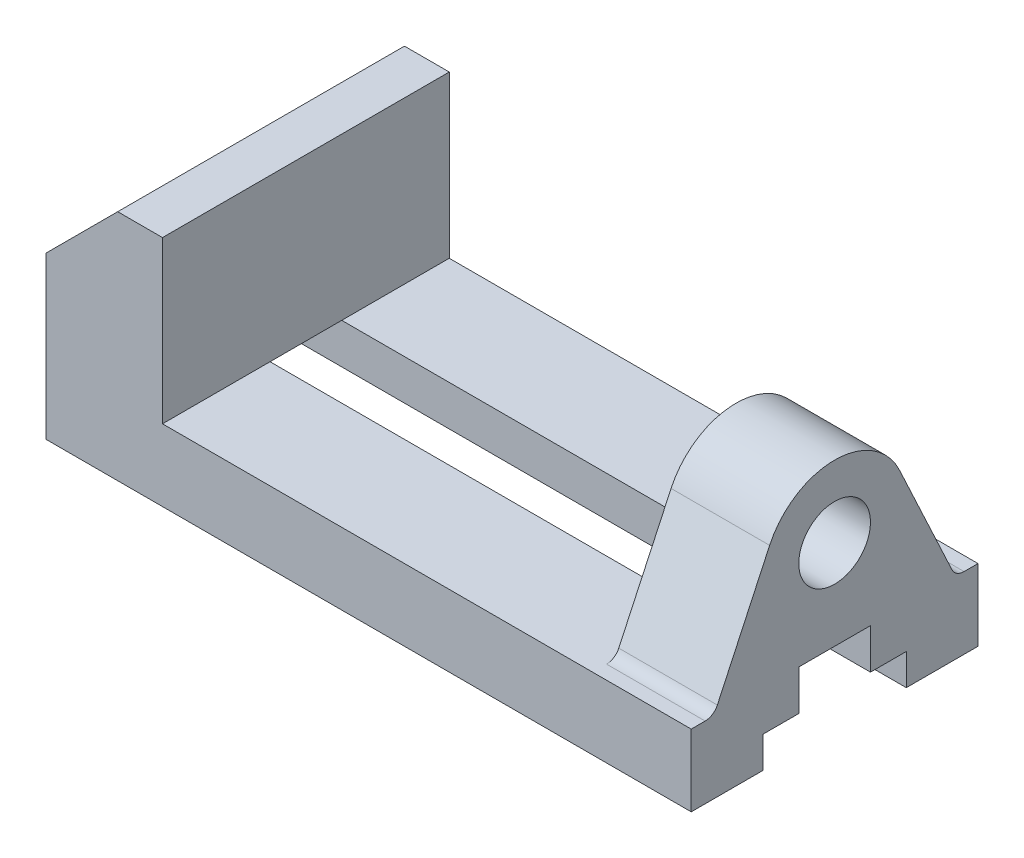
from build123d import *

# Parameters (mm, degrees)
SKETCH1_W                             = 144
SKETCH1_H                             = 64
BOSS_EXTRUDE1_DEPTH                   = 16
CUT_EXTRUDE1_REACH                    = 146
BOSS_EXTRUDE2_DEPTH                   = 32
SKETCH5_R                             = 8
BOSS_EXTRUDE3_DEPTH                   = 22
FILLET1_R                             = 3
TAP_DRILL_FOR_M6X1_0_TAP1_D           = 5
TAP_DRILL_FOR_M6X1_0_TAP1_DEPTH       = 8.497848452
TAP_DRILL_FOR_M6X1_0_TAP1_CSINK_D     = 5.05
TAP_DRILL_FOR_M6X1_0_TAP1_CSINK_ANGLE = 90
TAP_DRILL_FOR_M6X1_0_TAP1_TIP         = 1.502151548


with BuildPart() as part:
    # Sketch1 → Boss-Extrude1 (new body)
    with BuildSketch(Plane(origin=(0, 0, 0), x_dir=(1, 0, 0), z_dir=(0, 1, 0))):
        Rectangle(SKETCH1_W, SKETCH1_H)
    extrude(amount=-BOSS_EXTRUDE1_DEPTH)

    # Sketch2 → Cut-Extrude1 (cut, up to next)
    with BuildSketch(Plane(origin=(72, 0, 0), x_dir=(0, 0, -1), z_dir=(1, 0, 0)), mode=Mode.PRIVATE) as cut_extrude1_sk1:
        Polygon((-8, 0), (8, 0), (8, -9), (16, -9), (16, -16), (-16, -16), (-16, -9), (-8, -9), align=None)
    cut_extrude1_tool1 = extrude(cut_extrude1_sk1.sketch, amount=-CUT_EXTRUDE1_REACH, mode=Mode.PRIVATE) & part.part
    add(cut_extrude1_tool1.solids().sort_by_distance((72, -9.369565, 0))[0], mode=Mode.SUBTRACT)

    # Sketch4 → Boss-Extrude2 (add, symmetric)
    with BuildSketch(Plane.XY):
        Polygon((-72, 20), (-56, 36), (-46, 36), (-46, 0), (-72, 0), align=None)
    extrude(amount=BOSS_EXTRUDE2_DEPTH, both=True)

    # Sketch5 → Boss-Extrude3 (add)
    with BuildSketch(Plane(origin=(72, 0, 0), x_dir=(0, 0, -1), z_dir=(1, 0, 0))):
        with BuildLine():
            Line((26.980199866, 0), (14.500924593, 26.761892188))
            ThreePointArc((14.500924593, 26.761892188), (0, 36), (-14.500924593, 26.761892188))
            Line((-14.500924593, 26.761892188), (-26.980199866, 0))
            Line((-26.980199866, 0), (26.980199866, 0))
        make_face()
        with Locations((0, 20)):
            Circle(SKETCH5_R, mode=Mode.SUBTRACT)
    extrude(amount=-BOSS_EXTRUDE3_DEPTH)

    # Fillet1
    fillet1_edges = [part.edges().sort_by_distance(p)[0] for p in [
        (61, 0, -26.980199866),
        (61, 0, 26.980199866),
    ]]
    fillet(fillet1_edges, radius=FILLET1_R)

    # Tap Drill for M6x1.0 Tap1
    with Locations(Plane(origin=(0, -16, 0), x_dir=(-1, 0, 0), z_dir=(0, -1, 0))):
        with Locations((35, 22), (-35, 22), (35, -22), (-35, -22), (0, 0)):
            CounterSinkHole(TAP_DRILL_FOR_M6X1_0_TAP1_D / 2, TAP_DRILL_FOR_M6X1_0_TAP1_CSINK_D / 2, depth=TAP_DRILL_FOR_M6X1_0_TAP1_DEPTH, counter_sink_angle=TAP_DRILL_FOR_M6X1_0_TAP1_CSINK_ANGLE)
            with Locations((0, 0, -(TAP_DRILL_FOR_M6X1_0_TAP1_DEPTH + TAP_DRILL_FOR_M6X1_0_TAP1_TIP / 2))):  # 118° drill point
                Cone(0, TAP_DRILL_FOR_M6X1_0_TAP1_D / 2, TAP_DRILL_FOR_M6X1_0_TAP1_TIP, mode=Mode.SUBTRACT)


solid = part.part
